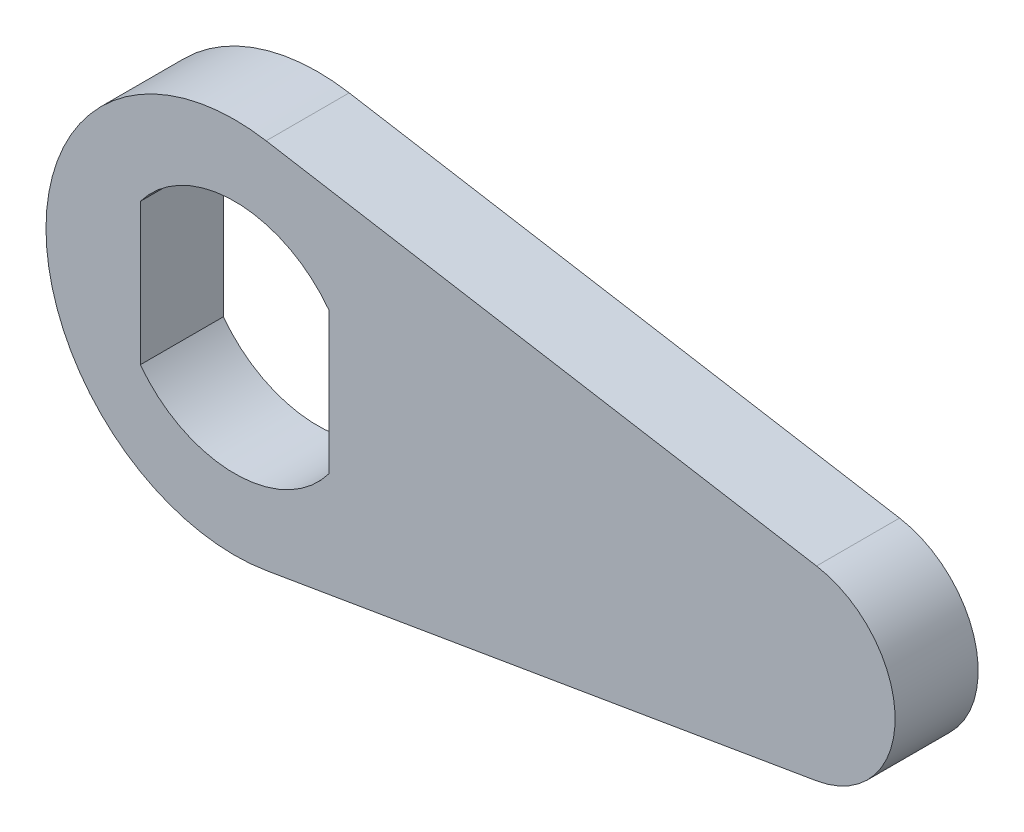
from build123d import *

# Parameters (mm, degrees)
BOSS_EXTRUDE1_DEPTH = 2.794


with BuildPart() as part:
    # Sketch1 → Boss-Extrude1 (new body)
    with BuildSketch(Plane.XY):
        with BuildLine():
            Line((1.058333333, 6.261184437), (19.579166667, 3.130592219))
            ThreePointArc((19.579166667, 3.130592219), (22.225, 0), (19.579166667, -3.130592219))
            Line((19.579166667, -3.130592219), (1.058333333, -6.261184437))
            ThreePointArc((1.058333333, -6.261184437), (-6.35, 0), (1.058333333, 6.261184437))
        make_face()
        with BuildLine():
            Line((-3.175, 2.38125), (-3.175, -2.38125))
            ThreePointArc((-3.175, -2.38125), (0, -3.96875), (3.175, -2.38125))
            Line((3.175, -2.38125), (3.175, 2.38125))
            ThreePointArc((3.175, 2.38125), (0, 3.96875), (-3.175, 2.38125))
        make_face(mode=Mode.SUBTRACT)
    extrude(amount=BOSS_EXTRUDE1_DEPTH)


solid = part.part
